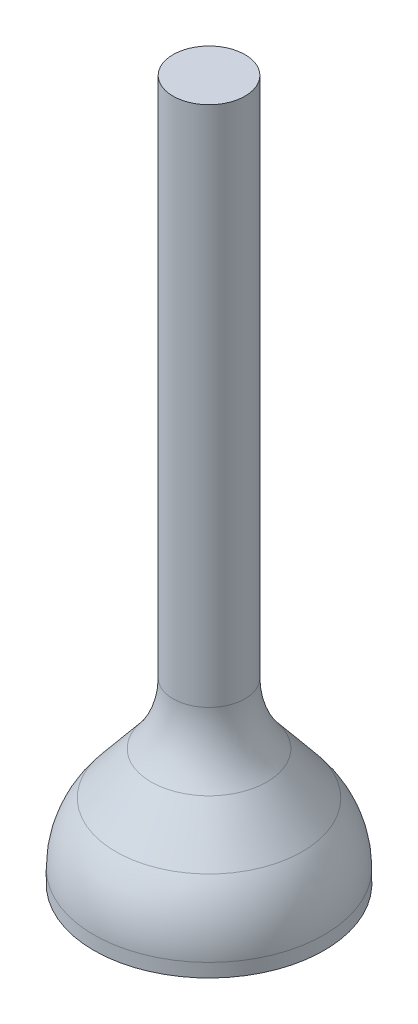
from build123d import *

# Parameters (mm, degrees)
SKETCH1_R           = 3.048
BOSS_EXTRUDE1_DEPTH = 1.27
SKETCH2_R           = 0.9525
SKETCH3_R           = 0.9525
BOSS_EXTRUDE2_DEPTH = 14.732
FILLET1_R           = 2.54


with BuildPart() as part:
    # Sketch1 → Boss-Extrude1 (new body)
    with BuildSketch(Plane(origin=(0, 0, 0), x_dir=(1, 0, 0), z_dir=(0, 1, 0))):
        with Locations(Location((0, 0, 0), (0, 0, 270))):
            Circle(SKETCH1_R)
    extrude(amount=BOSS_EXTRUDE1_DEPTH)

    # Sketch2 → section 0 of loft1
    with BuildSketch(Plane(origin=(0, 3.81, 0), x_dir=(1, 0, 0), z_dir=(0, 1, 0)), mode=Mode.PRIVATE) as loft1_s0:
        Circle(SKETCH2_R)
    # loft up to a face of the part (loft1)
    loft([loft1_s0.sketch, Face(Wire([part.edges().sort_by_distance((2.221896376, 1.27, -2.086499579))[0]]))])

    # Sketch3 → Boss-Extrude2 (add)
    with BuildSketch(Plane(origin=(0, 3.81, 0), x_dir=(1, 0, 0), z_dir=(0, 1, 0))):
        with Locations(Location((0, 0, 0), (0, 0, 90))):
            Circle(SKETCH3_R)
    extrude(amount=BOSS_EXTRUDE2_DEPTH)

    # Fillet1
    fillet1_edges = [part.edges().sort_by_distance(p)[0] for p in [
        (-2.155261469, 1.27, -2.155261469),
        (-0.673519209, 3.81, 0.673519209),
    ]]
    fillet(fillet1_edges, radius=FILLET1_R)


solid = part.part
